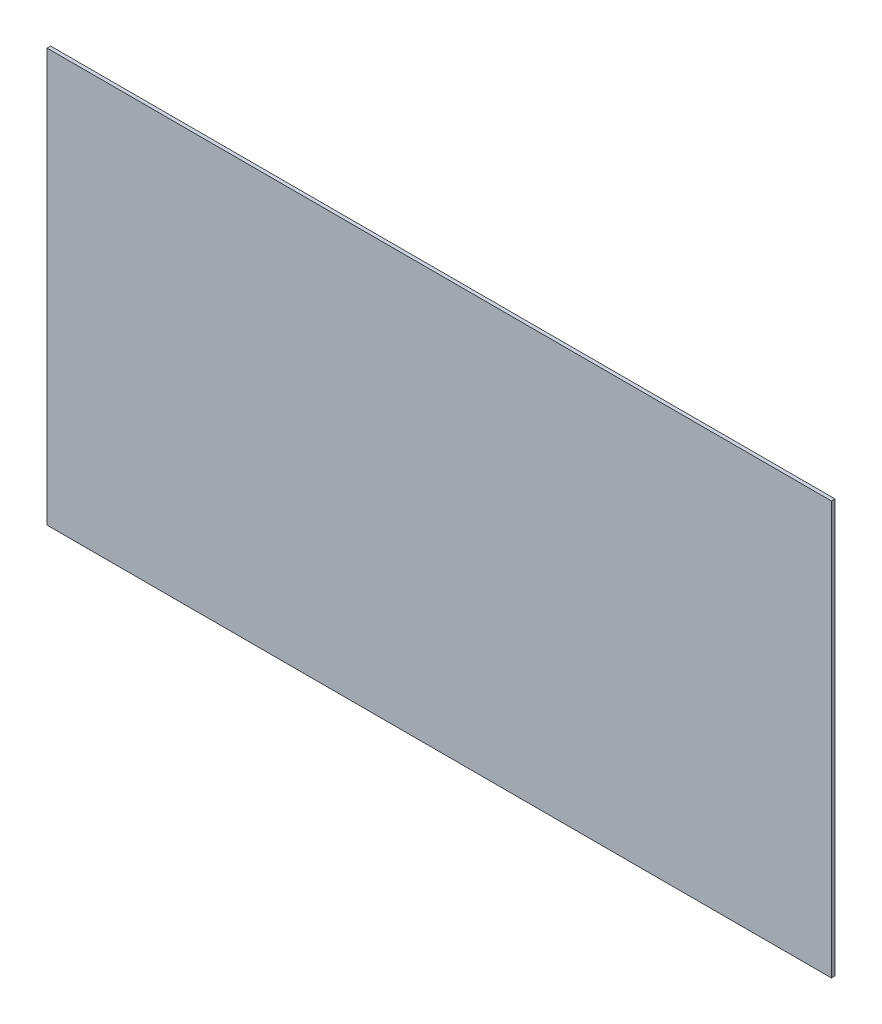
from build123d import *

# Parameters (mm, degrees)
SKETCH1_W      = 330.2
SKETCH1_H      = 173.9
EXTRUDE1_DEPTH = 0.75


with BuildPart() as part:
    # Sketch1 → Extrude1 (new body, symmetric)
    with BuildSketch(Plane.XY):
        with Locations((0, 875.48)):
            Rectangle(SKETCH1_W, SKETCH1_H)
    extrude(amount=EXTRUDE1_DEPTH, both=True)


solid = part.part
